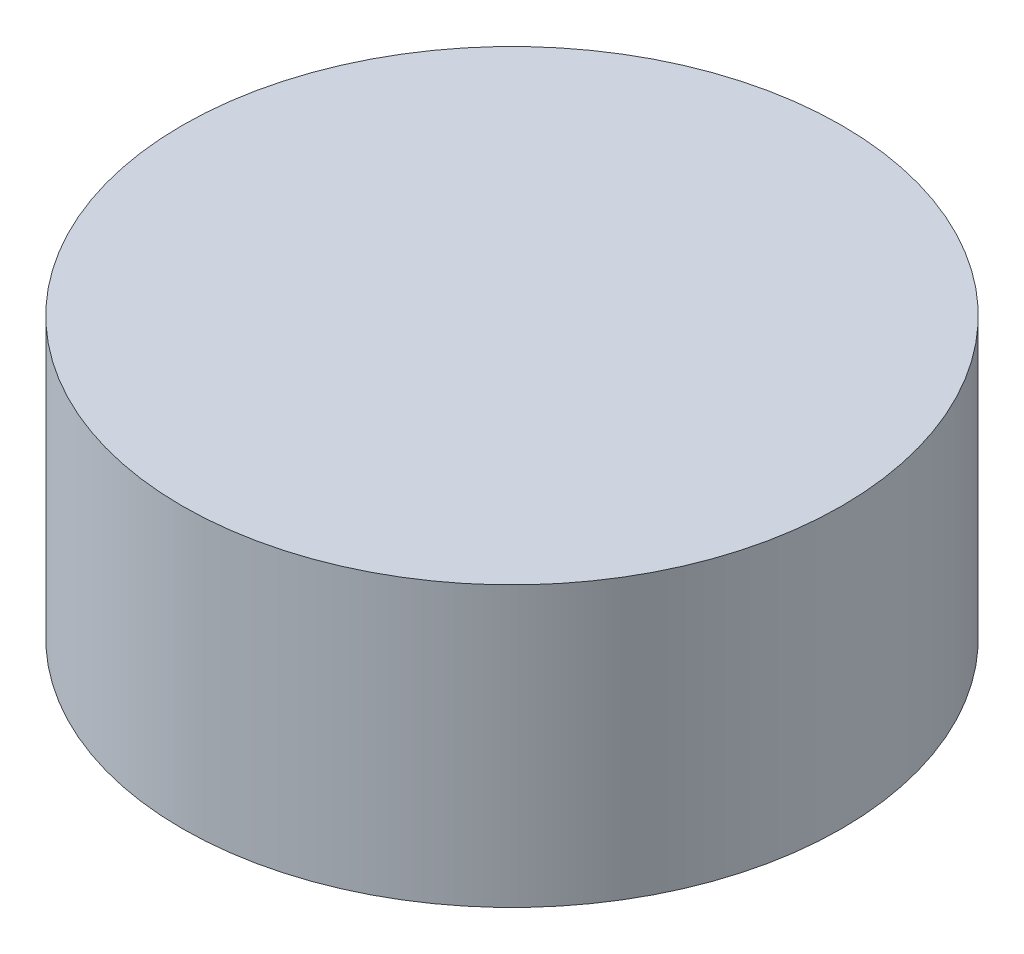
from build123d import *

# Parameters (mm, degrees)
SKETCH1_R           = 29.5
BOSS_EXTRUDE1_DEPTH = 12.5


with BuildPart() as part:
    # Sketch1 → Boss-Extrude1 (new body, symmetric)
    with BuildSketch(Plane(origin=(0, 0, 0), x_dir=(1, 0, 0), z_dir=(0, 1, 0))):
        Circle(SKETCH1_R)
    extrude(amount=BOSS_EXTRUDE1_DEPTH, both=True)


solid = part.part
